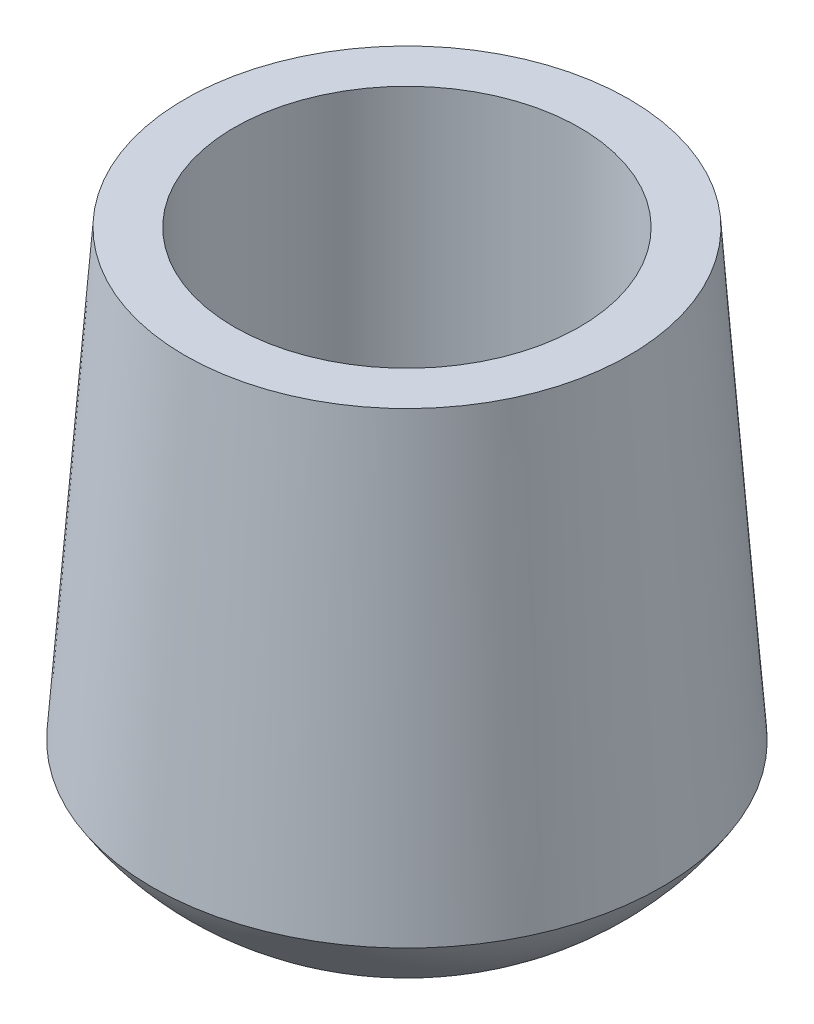
from build123d import *


with BuildPart() as part:
    # Sketch1 → Revolve1 (revolve)
    with BuildSketch(Plane.XY):
        with BuildLine():
            Line((0, 0), (-7, 0))
            Line((-7, 0), (-7, 18.59863153))
            Line((-7, 18.59863153), (-9, 18.59863153))
            Line((-9, 18.59863153), (-10.326901538, 0.59863153))
            ThreePointArc((-10.326901538, 0.59863153), (-5.894690382, -3.411656367), (0, -4.40136847))
            Line((0, -4.40136847), (0, 0))
        make_face()
    revolve(axis=Axis((0, 0, 0), (0, -1, 0)))


solid = part.part
